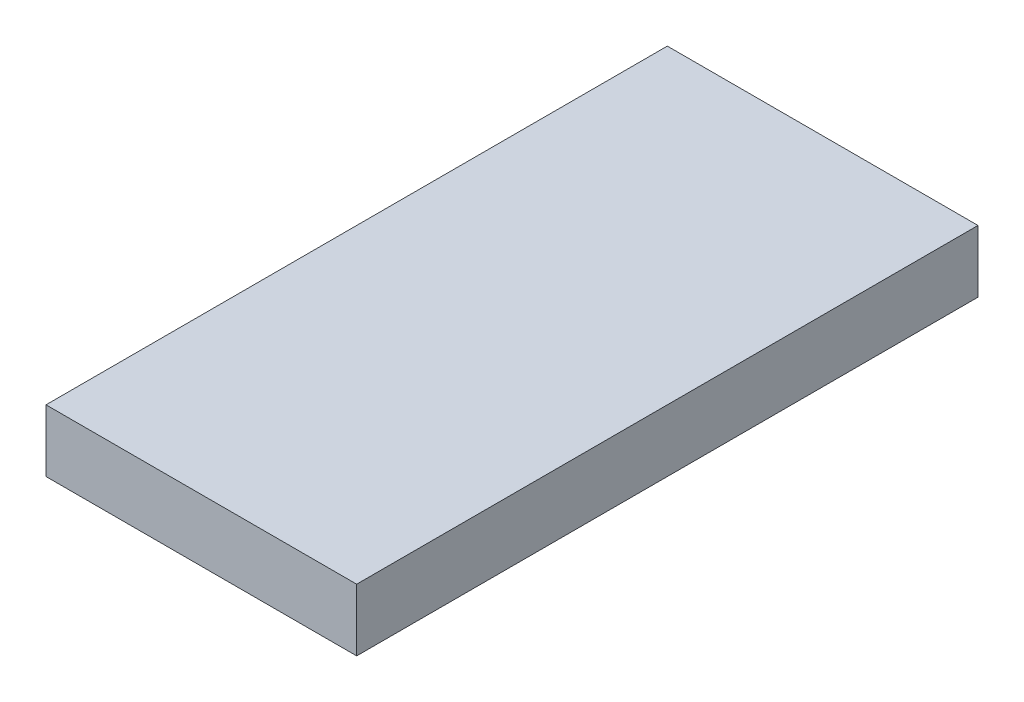
from build123d import *

# Parameters (mm, degrees)
SKETCH1_W           = 25.4
SKETCH1_H           = 50.8
BOSS_EXTRUDE1_DEPTH = 5.08


with BuildPart() as part:
    # Sketch1 → Boss-Extrude1 (new body)
    with BuildSketch(Plane(origin=(0, 0, 0), x_dir=(1, 0, 0), z_dir=(0, 1, 0))):
        with Locations((-10.365515292, -0.915068383)):
            Rectangle(SKETCH1_W, SKETCH1_H)
    extrude(amount=BOSS_EXTRUDE1_DEPTH)


solid = part.part
